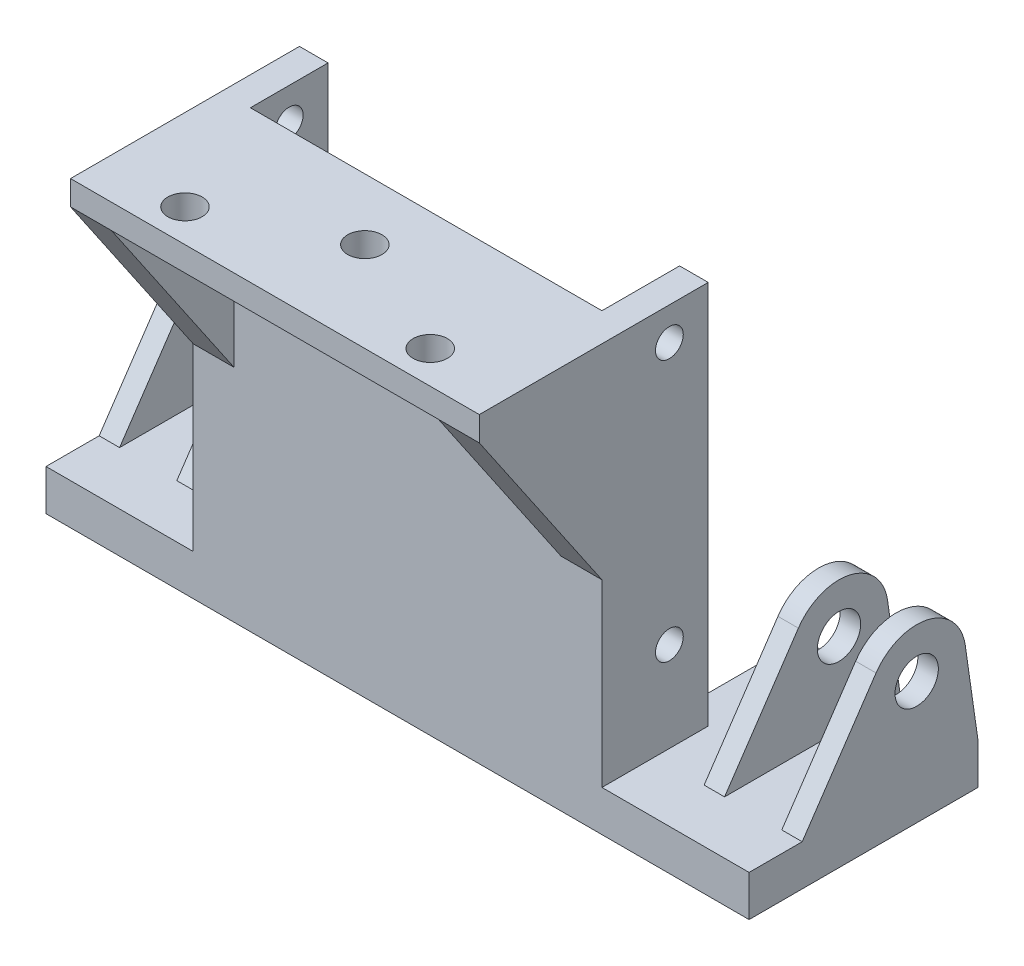
from build123d import *

# Parameters (mm, degrees)
SKETCH_1_W               = 50
SKETCH_1_H               = 40
EXTRUDE_1_DEPTH          = 5
SKETCH_2_W               = 6
SKETCH_2_H               = 40
EXTRUDE_2_DEPTH          = 8
SKETCH_4_W               = 38
SKETCH_4_H               = 40
CUT_EXTRUDE_2_DEPTH      = 1.5
SKETCH_6_R               = 1.7
CUT_EXTRUDE_3_DEPTH      = 45
CUT_EXTRUDE_3_DEPTH_BACK = 7
SKETCH_7_W               = 43
SKETCH_7_H               = 9.5
CUT_EXTRUDE_4_DEPTH      = 41
SKETCH_8_W               = 50
SKETCH_8_H               = 3
EXTRUDE_4_DEPTH          = 15
SKETCH_9_R               = 2.1
CUT_EXTRUDE_5_DEPTH      = 4
EXTRUDE_5_DEPTH          = 12
SKETCH_11_W              = 13
SKETCH_11_H              = 5
EXTRUDE_6_DEPTH          = 18
SKETCH_12_W              = 13
SKETCH_12_H              = 5
EXTRUDE_7_DEPTH          = 18
SKETCH_13_W              = 21.5
SKETCH_13_H              = 5
EXTRUDE_8_DEPTH          = 15
EXTRUDE_11_DEPTH         = 5
EXTRUDE_12_DEPTH         = 5
SKETCH_20_R              = 2.65
EXTRUDE_13_DEPTH         = 12
SKETCH_21_W              = 7
SKETCH_21_H              = 34.173261611
CUT_EXTRUDE_8_DEPTH      = 44


with BuildPart() as part:
    # 草图1 → 凸台-拉伸1 (new body)
    with BuildSketch(Plane.XY):
        Rectangle(SKETCH_1_W, SKETCH_1_H)
    extrude(amount=EXTRUDE_1_DEPTH)

    # 草图2 → 凸台-拉伸2 (add)
    with BuildSketch(Plane(origin=(0, 0, 0), x_dir=(-1, 0, 0), z_dir=(0, 0, -1))):
        with Locations((-22, 0)):
            Rectangle(SKETCH_2_W, SKETCH_2_H)
        with Locations((22, 0)):
            Rectangle(SKETCH_2_W, SKETCH_2_H)
    extrude(amount=EXTRUDE_2_DEPTH)

    # 草图4 → 切除-拉伸2 (cut)
    with BuildSketch(Plane(origin=(0, 0, 0), x_dir=(-1, 0, 0), z_dir=(0, 0, -1))):
        Rectangle(SKETCH_4_W, SKETCH_4_H)
    extrude(amount=-CUT_EXTRUDE_2_DEPTH, mode=Mode.SUBTRACT)

    # 草图6 → 切除-拉伸3 (cut, two sides)
    with BuildSketch(Plane(origin=(-19, 0, 0), x_dir=(0, 0, -1), z_dir=(1, 0, 0))) as cut_extrude_3_sk:
        with Locations((3.25, 16)):
            Circle(SKETCH_6_R)
        with Locations((3.25, -16)):
            Circle(SKETCH_6_R)
    extrude(amount=CUT_EXTRUDE_3_DEPTH, mode=Mode.SUBTRACT)
    extrude(cut_extrude_3_sk.sketch, amount=-CUT_EXTRUDE_3_DEPTH_BACK, mode=Mode.SUBTRACT)

    # 草图7 → 切除-拉伸4 (cut, through all)
    with BuildSketch(Plane.XZ.offset(20)):
        with Locations((0, -3.25)):
            Rectangle(SKETCH_7_W, SKETCH_7_H)
    extrude(amount=-CUT_EXTRUDE_4_DEPTH, mode=Mode.SUBTRACT)

    # 草图8 → 凸台-拉伸4 (add)
    with BuildSketch(Plane.XY.offset(5)):
        with Locations((0, 18.5)):
            Rectangle(SKETCH_8_W, SKETCH_8_H)
    extrude(amount=EXTRUDE_4_DEPTH)

    # 草图9 → 切除-拉伸5 (cut, through all)
    with BuildSketch(Plane.XZ.offset(-17)):
        with Locations((-15, 16)):
            Circle(SKETCH_9_R)
        with Locations((15, 16)):
            Circle(SKETCH_9_R)
        with Locations((0, 9)):
            Circle(SKETCH_9_R)
    extrude(amount=-CUT_EXTRUDE_5_DEPTH, mode=Mode.SUBTRACT)

    # 草图10 → 凸台-拉伸5 (add)
    with BuildSketch(Plane.XZ.offset(20)):
        Polygon((-25, -8), (-21.5, -8), (-21.5, 1.5), (21.5, 1.5), (21.5, -8), (25, -8), (25, 5), (-25, 5), align=None)
    extrude(amount=EXTRUDE_5_DEPTH)

    # 草图11 → 凸台-拉伸6 (add)
    with BuildSketch(Plane(origin=(25, 0, 0), x_dir=(0, 0, -1), z_dir=(1, 0, 0))):
        with Locations((1.5, -29.5)):
            Rectangle(SKETCH_11_W, SKETCH_11_H)
    extrude(amount=EXTRUDE_6_DEPTH)

    # 草图12 → 凸台-拉伸7 (add)
    with BuildSketch(Plane.ZY.offset(25)):
        with Locations((-1.5, -29.5)):
            Rectangle(SKETCH_12_W, SKETCH_12_H)
    extrude(amount=EXTRUDE_7_DEPTH)

    # 草图13 → 凸台-拉伸8 (add)
    with BuildSketch(Plane(origin=(0, 0, -8), x_dir=(-1, 0, 0), z_dir=(0, 0, -1))):
        with Locations((32.25, -29.5)):
            Rectangle(SKETCH_13_W, SKETCH_13_H)
        with Locations((-32.25, -29.5)):
            Rectangle(SKETCH_13_W, SKETCH_13_H)
    extrude(amount=EXTRUDE_8_DEPTH)

    # 草图18 → 凸台-拉伸11 (add)
    with BuildSketch(Plane.ZY.offset(25)):
        Polygon((5, -5), (20, 17), (5, 17), align=None)
    extrude(amount=-EXTRUDE_11_DEPTH)

    # 草图19 → 凸台-拉伸12 (add)
    with BuildSketch(Plane(origin=(25, 0, 0), x_dir=(0, 0, -1), z_dir=(1, 0, 0))):
        Polygon((-5, 17), (-5, -5), (-20, 17), align=None)
    extrude(amount=-EXTRUDE_12_DEPTH)

    # 草图20 → 凸台-拉伸13 (add)
    with BuildSketch(Plane.ZY.offset(43)):
        with BuildLine():
            Line((-23, -27), (-21.438888742, -16.145833443))
            ThreePointArc((-21.438888742, -16.145833443), (-16.842939484, -11.152221487), (-10.528814426, -13.640340197))
            Line((-10.528814426, -13.640340197), (-1.5, -27))
            Line((-1.5, -27), (-23, -27))
        make_face()
        with Locations((-15.5, -17)):
            Circle(SKETCH_20_R, mode=Mode.SUBTRACT)
    extrude_13 = extrude(amount=-EXTRUDE_13_DEPTH)

    # 草图21 → 切除-拉伸8 (cut, through all)
    with BuildSketch(Plane(origin=(0, 0, -23), x_dir=(-1, 0, 0), z_dir=(0, 0, -1))):
        with Locations((37, -9.913369194)):
            Rectangle(SKETCH_21_W, SKETCH_21_H)
    cut_extrude_8 = extrude(amount=-CUT_EXTRUDE_8_DEPTH, mode=Mode.SUBTRACT)

    # 镜向3: 凸台-拉伸13, 切除-拉伸8 across plane
    add(extrude_13.mirror(Plane(origin=(0, 0, 0), x_dir=(0, 0, 1), z_dir=(1, 0, 0))))
    add(cut_extrude_8.mirror(Plane(origin=(0, 0, 0), x_dir=(0, 0, 1), z_dir=(1, 0, 0))), mode=Mode.SUBTRACT)


solid = part.part
